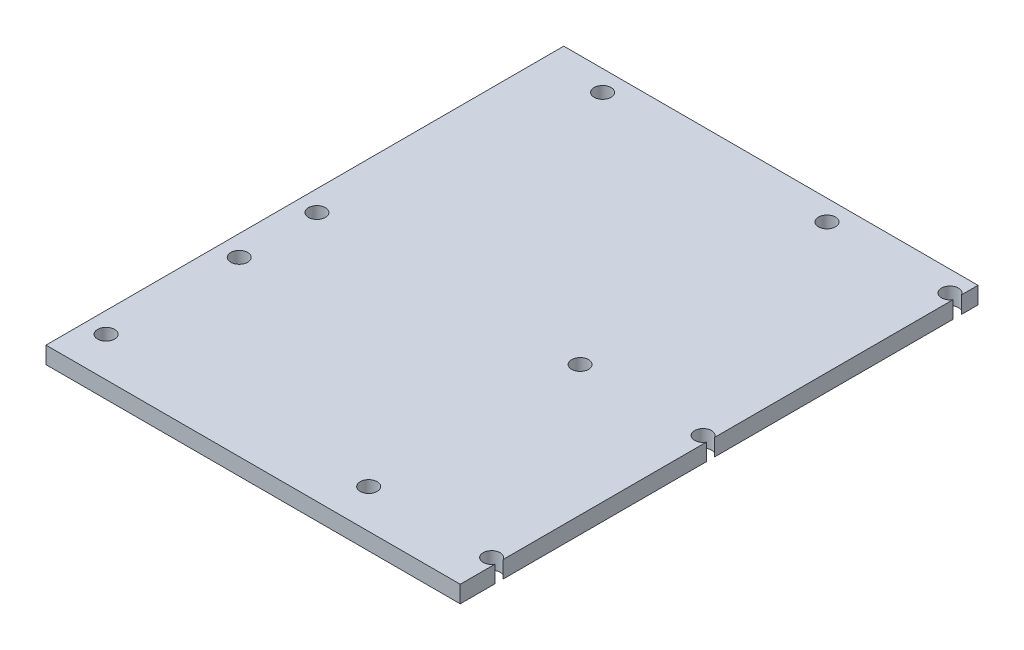
from build123d import *

# Parameters (mm, degrees)
SKETCH2_W           = 243.84
SKETCH2_H           = 304.8
BOSS_EXTRUDE1_DEPTH = 10
SKETCH1_R           = 5
CUT_EXTRUDE2_DEPTH  = 10


with BuildPart() as part:
    # Sketch2 → Boss-Extrude1 (new body)
    with BuildSketch(Plane(origin=(0, 0, 0), x_dir=(1, 0, 0), z_dir=(0, 1, 0))):
        Rectangle(SKETCH2_W, SKETCH2_H)
    extrude(amount=BOSS_EXTRUDE1_DEPTH)

    # Sketch1 → Cut-Extrude2 (cut)
    with BuildSketch(Plane(origin=(0, 0, 0), x_dir=(1, 0, 0), z_dir=(0, 1, 0))):
        with Locations((-86.9, 140.24)):
            Circle(SKETCH1_R)
        with Locations((45.18, 140.24)):
            Circle(SKETCH1_R)
        with Locations((117.57, 140.24)):
            Circle(SKETCH1_R)
        with Locations((117.57, -5.08)):
            Circle(SKETCH1_R)
        with Locations((45.18, -5.08)):
            Circle(SKETCH1_R)
        with Locations((-109.76, -5.08)):
            Circle(SKETCH1_R)
        with Locations((-109.76, -50.8)):
            Circle(SKETCH1_R)
        with Locations((-109.76, -129.196094703)):
            Circle(SKETCH1_R)
        with Locations((45.18, -129.54)):
            Circle(SKETCH1_R)
        with Locations((117.57, -129.54)):
            Circle(SKETCH1_R)
    extrude(amount=CUT_EXTRUDE2_DEPTH, mode=Mode.SUBTRACT)


solid = part.part
